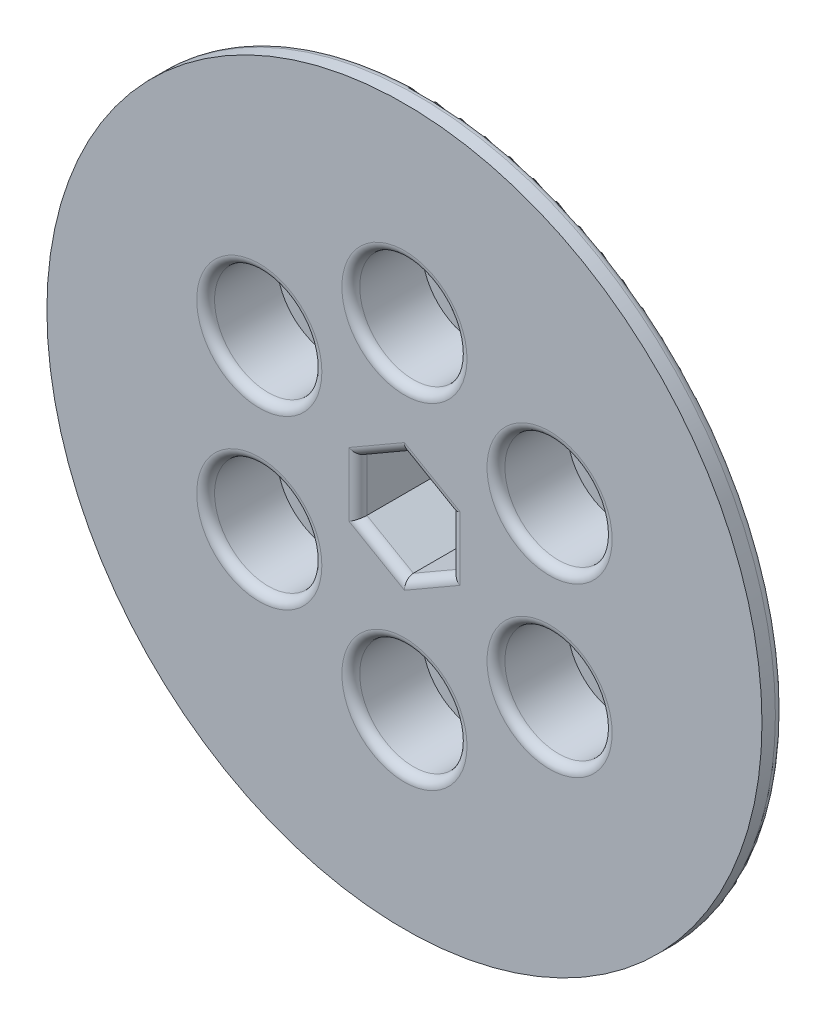
from build123d import *

# Parameters (mm, degrees)
SKETCH1_R           = 31.75
BOSS_EXTRUDE1_DEPTH = 12.7
SKETCH2_R           = 50.8
BOSS_EXTRUDE2_DEPTH = 3.175
CUT_EXTRUDE_R_REACH = 17.875
SKETCH3_R           = 2.667
SKETCH4_R           = 7.62
CUT_EXTRUDE2_DEPTH  = 10.16
FILLET1_R           = 1.27


with BuildPart() as part:
    # Sketch1 → Boss-Extrude1 (new body)
    with BuildSketch(Plane.XY):
        Circle(SKETCH1_R)
    extrude(amount=BOSS_EXTRUDE1_DEPTH)

    # Sketch2 → Boss-Extrude2 (add)
    with BuildSketch(Plane.XY.offset(12.7)):
        Circle(SKETCH2_R)
    extrude(amount=BOSS_EXTRUDE2_DEPTH)

    # Sketch3 → Cut-Extrude r (cut, up to next)
    with BuildSketch(Plane(origin=(0, 0, 0), x_dir=(-1, 0, 0), z_dir=(0, 0, -1)), mode=Mode.PRIVATE) as cut_extrude_r_sk1:
        with Locations((0, 23.8125)):
            Circle(SKETCH3_R)
    cut_extrude_r_tool1 = extrude(cut_extrude_r_sk1.sketch, amount=-CUT_EXTRUDE_R_REACH, mode=Mode.PRIVATE) & part.part
    add(cut_extrude_r_tool1.solids().sort_by_distance((0, 23.8125, 0))[0], mode=Mode.SUBTRACT)
    # Sketch3 → Cut-Extrude r (cut, up to next)
    with BuildSketch(Plane(origin=(0, 0, 0), x_dir=(-1, 0, 0), z_dir=(0, 0, -1)), mode=Mode.PRIVATE) as cut_extrude_r_sk2:
        with Locations((20.622229928, 11.90625)):
            Circle(SKETCH3_R)
    cut_extrude_r_tool2 = extrude(cut_extrude_r_sk2.sketch, amount=-CUT_EXTRUDE_R_REACH, mode=Mode.PRIVATE) & part.part
    add(cut_extrude_r_tool2.solids().sort_by_distance((-20.62223, 11.90625, 0))[0], mode=Mode.SUBTRACT)
    # Sketch3 → Cut-Extrude r (cut, up to next)
    with BuildSketch(Plane(origin=(0, 0, 0), x_dir=(-1, 0, 0), z_dir=(0, 0, -1)), mode=Mode.PRIVATE) as cut_extrude_r_sk3:
        with Locations((20.622229928, -11.90625)):
            Circle(SKETCH3_R)
    cut_extrude_r_tool3 = extrude(cut_extrude_r_sk3.sketch, amount=-CUT_EXTRUDE_R_REACH, mode=Mode.PRIVATE) & part.part
    add(cut_extrude_r_tool3.solids().sort_by_distance((-20.62223, -11.90625, 0))[0], mode=Mode.SUBTRACT)
    # Sketch3 → Cut-Extrude r (cut, up to next)
    with BuildSketch(Plane(origin=(0, 0, 0), x_dir=(-1, 0, 0), z_dir=(0, 0, -1)), mode=Mode.PRIVATE) as cut_extrude_r_sk4:
        with Locations((0, -23.8125)):
            Circle(SKETCH3_R)
    cut_extrude_r_tool4 = extrude(cut_extrude_r_sk4.sketch, amount=-CUT_EXTRUDE_R_REACH, mode=Mode.PRIVATE) & part.part
    add(cut_extrude_r_tool4.solids().sort_by_distance((0, -23.8125, 0))[0], mode=Mode.SUBTRACT)
    # Sketch3 → Cut-Extrude r (cut, up to next)
    with BuildSketch(Plane(origin=(0, 0, 0), x_dir=(-1, 0, 0), z_dir=(0, 0, -1)), mode=Mode.PRIVATE) as cut_extrude_r_sk5:
        with Locations((-20.622229928, -11.90625)):
            Circle(SKETCH3_R)
    cut_extrude_r_tool5 = extrude(cut_extrude_r_sk5.sketch, amount=-CUT_EXTRUDE_R_REACH, mode=Mode.PRIVATE) & part.part
    add(cut_extrude_r_tool5.solids().sort_by_distance((20.62223, -11.90625, 0))[0], mode=Mode.SUBTRACT)
    # Sketch3 → Cut-Extrude r (cut, up to next)
    with BuildSketch(Plane(origin=(0, 0, 0), x_dir=(-1, 0, 0), z_dir=(0, 0, -1)), mode=Mode.PRIVATE) as cut_extrude_r_sk6:
        with Locations((-20.622229928, 11.90625)):
            Circle(SKETCH3_R)
    cut_extrude_r_tool6 = extrude(cut_extrude_r_sk6.sketch, amount=-CUT_EXTRUDE_R_REACH, mode=Mode.PRIVATE) & part.part
    add(cut_extrude_r_tool6.solids().sort_by_distance((20.62223, 11.90625, 0))[0], mode=Mode.SUBTRACT)
    # Sketch3 → Cut-Extrude r (cut, up to next)
    with BuildSketch(Plane(origin=(0, 0, 0), x_dir=(-1, 0, 0), z_dir=(0, 0, -1)), mode=Mode.PRIVATE) as cut_extrude_r_sk7:
        Polygon((0, 7.625642355), (-6.604, 3.812821178), (-6.604, -3.812821178), (0, -7.625642355), (6.604, -3.812821178), (6.604, 3.812821178), align=None)
    cut_extrude_r_tool7 = extrude(cut_extrude_r_sk7.sketch, amount=-CUT_EXTRUDE_R_REACH, mode=Mode.PRIVATE) & part.part
    add(cut_extrude_r_tool7.solids().sort_by_distance((0, 0, 0))[0], mode=Mode.SUBTRACT)

    # Sketch4 → Cut-Extrude2 (cut)
    with BuildSketch(Plane.XY.offset(15.875)):
        with Locations((-20.622229928, -11.90625)):
            Circle(SKETCH4_R)
        with Locations((-20.622229928, 11.90625)):
            Circle(SKETCH4_R)
        with Locations((0, 23.8125)):
            Circle(SKETCH4_R)
        with Locations((20.622229928, 11.90625)):
            Circle(SKETCH4_R)
        with Locations((20.622229928, -11.90625)):
            Circle(SKETCH4_R)
        with Locations((0, -23.8125)):
            Circle(SKETCH4_R)
    extrude(amount=-CUT_EXTRUDE2_DEPTH, mode=Mode.SUBTRACT)

    # Fillet1
    fillet1_edges = [part.edges().sort_by_distance(p)[0] for p in [
        (-3.302, 5.719231767, 15.875),
        (-6.604, 0, 15.875),
        (-3.302, -5.719231767, 15.875),
        (3.302, -5.719231767, 15.875),
        (6.604, 0, 15.875),
        (3.302, 5.719231767, 15.875),
        (-50.8, 0, 12.7),
        (-28.242229928, 11.90625, 15.875),
        (-7.62, 23.8125, 15.875),
        (13.002229928, 11.90625, 15.875),
        (13.002229928, -11.90625, 15.875),
        (-7.62, -23.8125, 15.875),
        (-28.242229928, -11.90625, 15.875),
    ]]
    fillet(fillet1_edges, radius=FILLET1_R)


solid = part.part
